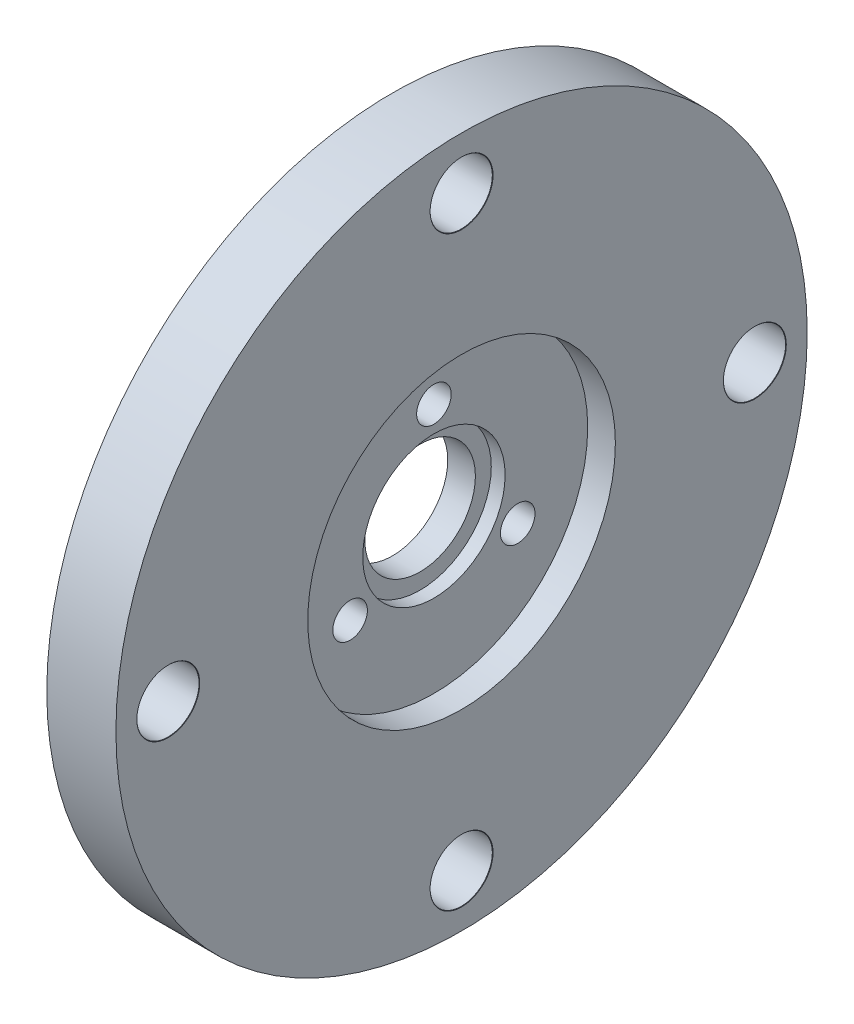
from build123d import *

# Parameters (mm, degrees)
SKETCH1_R                      = 25
SKETCH1_R_2                    = 4
BOSS_EXTRUDE1_DEPTH            = 5
SKETCH2_R                      = 5.15
CUT_EXTRUDE1_DEPTH             = 3
SKETCH3_R                      = 11.125
CUT_EXTRUDE2_DEPTH             = 2
SKETCH4_R                      = 1.25
CUT_EXTRUDE3_DEPTH             = 4
M4_CLEARANCE_HOLE1_D           = 4.5
M4_CLEARANCE_HOLE1_DEPTH       = 7.6
M4_CLEARANCE_HOLE1_CSINK_D     = 4.55
M4_CLEARANCE_HOLE1_CSINK_ANGLE = 90
M4_CLEARANCE_HOLE1_TIP         = 1.351936393


with BuildPart() as part:
    # Sketch1 → Boss-Extrude1 (new body)
    with BuildSketch(Plane(origin=(0, 0, 0), x_dir=(0, 0, -1), z_dir=(1, 0, 0))):
        Circle(SKETCH1_R)
        Circle(SKETCH1_R_2, mode=Mode.SUBTRACT)
    extrude(amount=BOSS_EXTRUDE1_DEPTH)

    # Sketch2 → Cut-Extrude1 (cut)
    with BuildSketch(Plane(origin=(5, 0, 0), x_dir=(0, 0, -1), z_dir=(1, 0, 0))):
        Circle(SKETCH2_R)
    extrude(amount=-CUT_EXTRUDE1_DEPTH, mode=Mode.SUBTRACT)

    # Sketch3 → Cut-Extrude2 (cut)
    with BuildSketch(Plane(origin=(5, 0, 0), x_dir=(0, 0, -1), z_dir=(1, 0, 0))):
        Circle(SKETCH3_R)
    extrude(amount=-CUT_EXTRUDE2_DEPTH, mode=Mode.SUBTRACT)

    # Sketch4 → Cut-Extrude3 (cut, through all)
    with BuildSketch(Plane(origin=(3, 0, 0), x_dir=(0, 0, -1), z_dir=(1, 0, 0))):
        with Locations((0, 7)):
            Circle(SKETCH4_R)
        with Locations((6.062177826, -3.5)):
            Circle(SKETCH4_R)
        with Locations((-6.062177826, -3.5)):
            Circle(SKETCH4_R)
    extrude(amount=-CUT_EXTRUDE3_DEPTH, mode=Mode.SUBTRACT)

    # M4 Clearance Hole1
    with Locations(Plane(origin=(5, 0, 0), x_dir=(0, 0, -1), z_dir=(1, 0, 0))):
        with Locations((0, 21.213203436), (21.213203436, 0), (-21.213203436, 0), (0, -21.213203436)):
            CounterSinkHole(M4_CLEARANCE_HOLE1_D / 2, M4_CLEARANCE_HOLE1_CSINK_D / 2, depth=M4_CLEARANCE_HOLE1_DEPTH, counter_sink_angle=M4_CLEARANCE_HOLE1_CSINK_ANGLE)
            with Locations((0, 0, -(M4_CLEARANCE_HOLE1_DEPTH + M4_CLEARANCE_HOLE1_TIP / 2))):  # 118° drill point
                Cone(0, M4_CLEARANCE_HOLE1_D / 2, M4_CLEARANCE_HOLE1_TIP, mode=Mode.SUBTRACT)


solid = part.part
